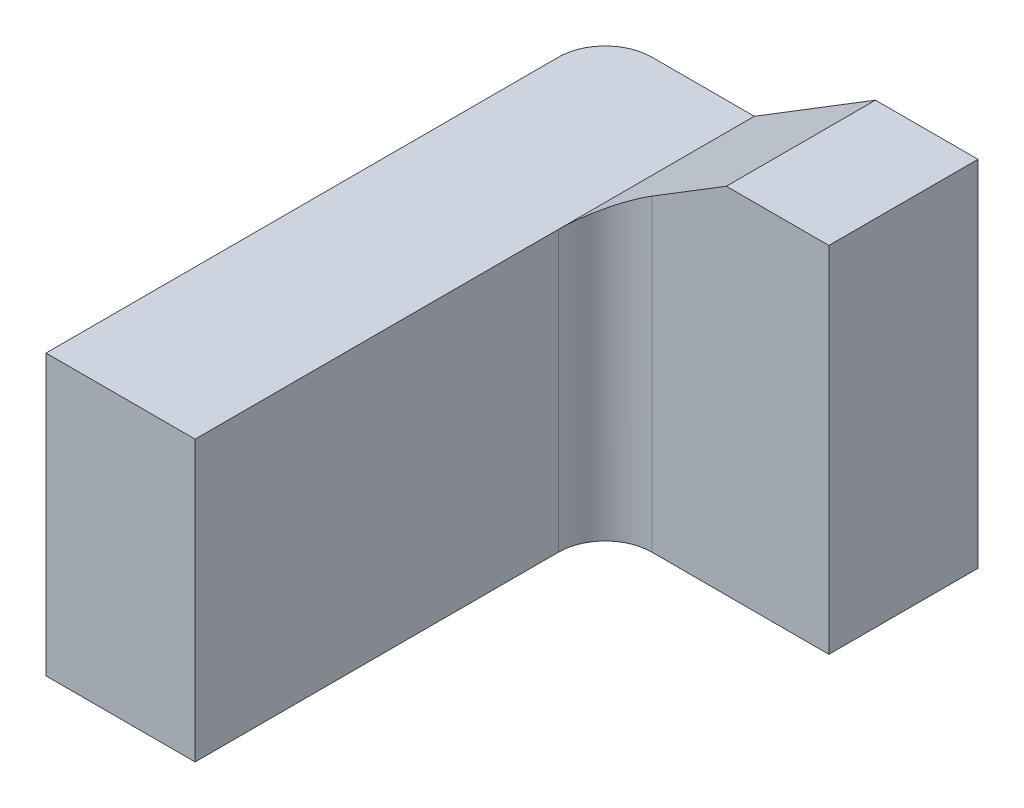
from build123d import *

# Parameters (mm, degrees)
EXTRUDE_1_DEPTH = 0.16
SKETCH_2_W      = 0.16
SKETCH_2_H      = 0.3
EXTRUDE_2_DEPTH = 0.44
FILLET_1_R      = 0.05


with BuildPart() as part:
    # 草图1 → 凸台-拉伸1 (new body)
    with BuildSketch(Plane.XY):
        Polygon((0, 0), (0, 0.3), (0.16, 0.3), (0.29, 0.38), (0.4, 0.38), (0.4, 0), align=None)
    extrude(amount=EXTRUDE_1_DEPTH)

    # 草图2 → 凸台-拉伸2 (add)
    with BuildSketch(Plane.XY.offset(0.16)):
        with Locations((0.08, 0.15)):
            Rectangle(SKETCH_2_W, SKETCH_2_H)
    extrude(amount=EXTRUDE_2_DEPTH)

    # 圆角1
    fillet_1_edges = [part.edges().sort_by_distance(p)[0] for p in [
        (0.16, 0.15, 0.16),
        (0, 0.15, 0),
    ]]
    fillet(fillet_1_edges, radius=FILLET_1_R)


solid = part.part
